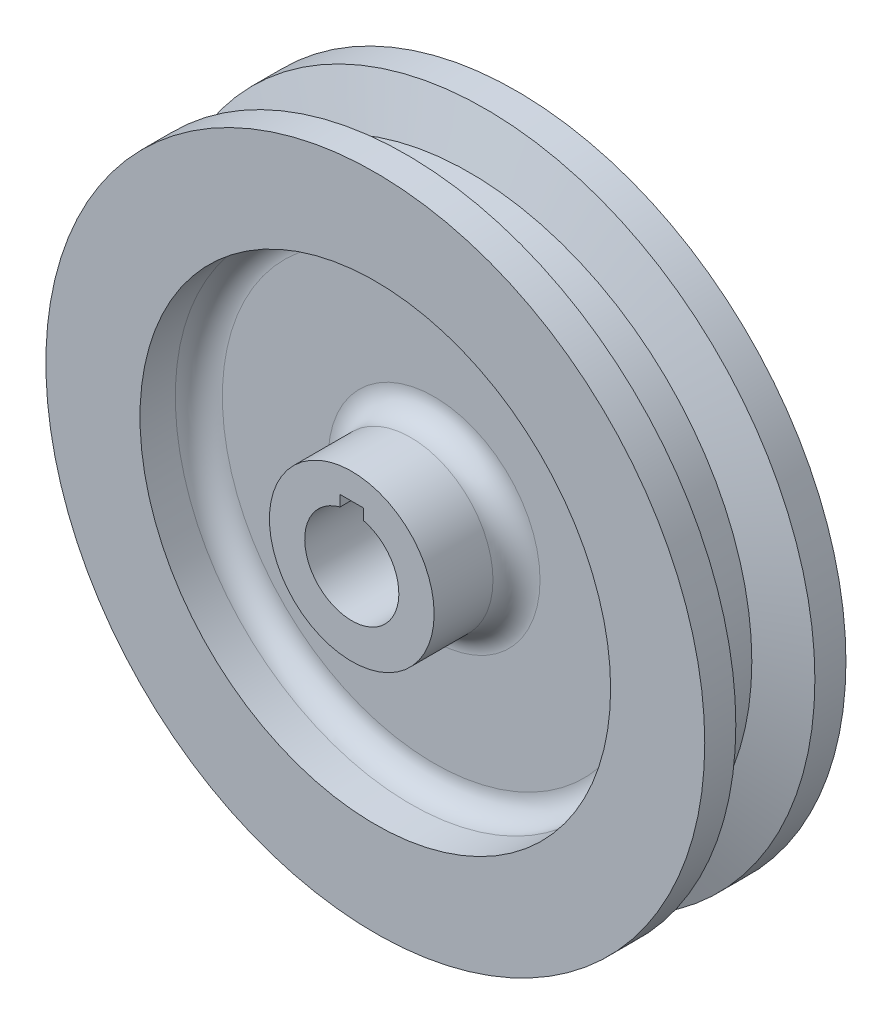
from build123d import *

# Parameters (mm, degrees)
SKETCH2_W          = 0.25
SKETCH2_H          = 0.370788844
CUT_EXTRUDE1_DEPTH = 20.6248


with BuildPart() as part:
    # Sketch1 → Revolve1 (revolve)
    with BuildSketch(Plane(origin=(0, 0, 0), x_dir=(0, 0, -1), z_dir=(1, 0, 0))):
        with BuildLine():
            Line((1, 0.875), (0.375, 0.875))
            ThreePointArc((0.375, 0.875), (0.198223305, 0.948223305), (0.125, 1.125))
            Line((0.125, 1.125), (0.125, 2.25))
            ThreePointArc((0.125, 2.25), (0.198223305, 2.426776695), (0.375, 2.5))
            Line((0.375, 2.5), (0.75, 2.5))
            Line((0.75, 2.5), (0.75, 3.5))
            Line((0.75, 3.5), (0.42, 3.5))
            Line((0.42, 3.5), (0.25, 3))
            Line((0.25, 3), (-0.25, 3))
            Line((-0.25, 3), (-0.42, 3.5))
            Line((-0.42, 3.5), (-0.75, 3.5))
            Line((-0.75, 3.5), (-0.75, 2.5))
            Line((-0.75, 2.5), (-0.375, 2.5))
            ThreePointArc((-0.375, 2.5), (-0.198223305, 2.426776695), (-0.125, 2.25))
            Line((-0.125, 2.25), (-0.125, 1.125))
            ThreePointArc((-0.125, 1.125), (-0.198223305, 0.948223305), (-0.375, 0.875))
            Line((-0.375, 0.875), (-1, 0.875))
            Line((-1, 0.875), (-1, 0.5))
            Line((-1, 0.5), (1, 0.5))
            Line((1, 0.5), (1, 0.875))
        make_face()
    revolve(axis=Axis((0, 0, 1.479906814), (0, 0, -1)))

    # Sketch2 → Cut-Extrude1 (cut)
    with BuildSketch(Plane.XY.offset(1)):
        with Locations((0, 0.414605578)):
            Rectangle(SKETCH2_W, SKETCH2_H)
    extrude(amount=-CUT_EXTRUDE1_DEPTH, mode=Mode.SUBTRACT)


solid = part.part
